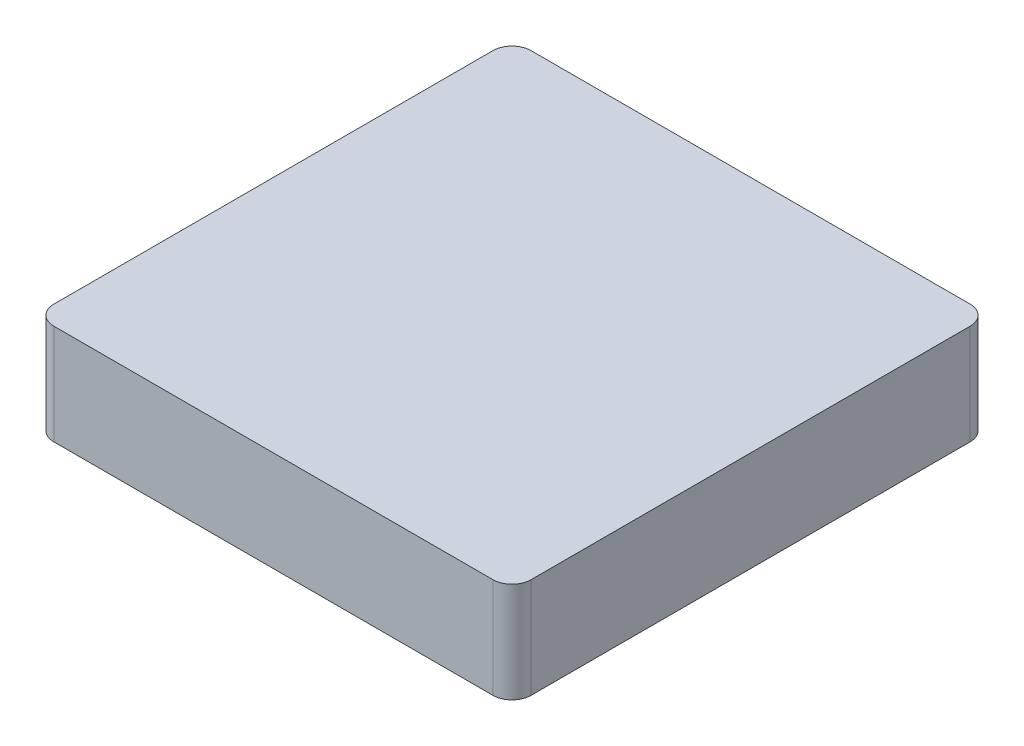
from build123d import *

# Parameters (mm, degrees)
SKETCH_1_W      = 50
SKETCH_1_H      = 50
EXTRUDE_1_DEPTH = 10
SKETCH_2_W      = 50
SKETCH_2_H      = 50
EXTRUDE_2_DEPTH = 0.5
FILLET_1_R      = 2


with BuildPart() as part:
    # 草图1 → 凸台-拉伸1 (new body)
    with BuildSketch(Plane(origin=(0, 0, 0), x_dir=(1, 0, 0), z_dir=(0, 1, 0))):
        Rectangle(SKETCH_1_W, SKETCH_1_H)
    extrude(amount=EXTRUDE_1_DEPTH)

    # 草图2 → 凸台-拉伸2 (add)
    with BuildSketch(Plane(origin=(0, 10, 0), x_dir=(1, 0, 0), z_dir=(0, 1, 0))):
        Rectangle(SKETCH_2_W, SKETCH_2_H)
    extrude(amount=EXTRUDE_2_DEPTH)

    # 圆角1
    fillet_1_edges = [part.edges().sort_by_distance(p)[0] for p in [
        (25, 5.25, 25),
        (-25, 5.25, 25),
        (-25, 5.25, -25),
        (25, 5.25, -25),
    ]]
    fillet(fillet_1_edges, radius=FILLET_1_R)


solid = part.part
